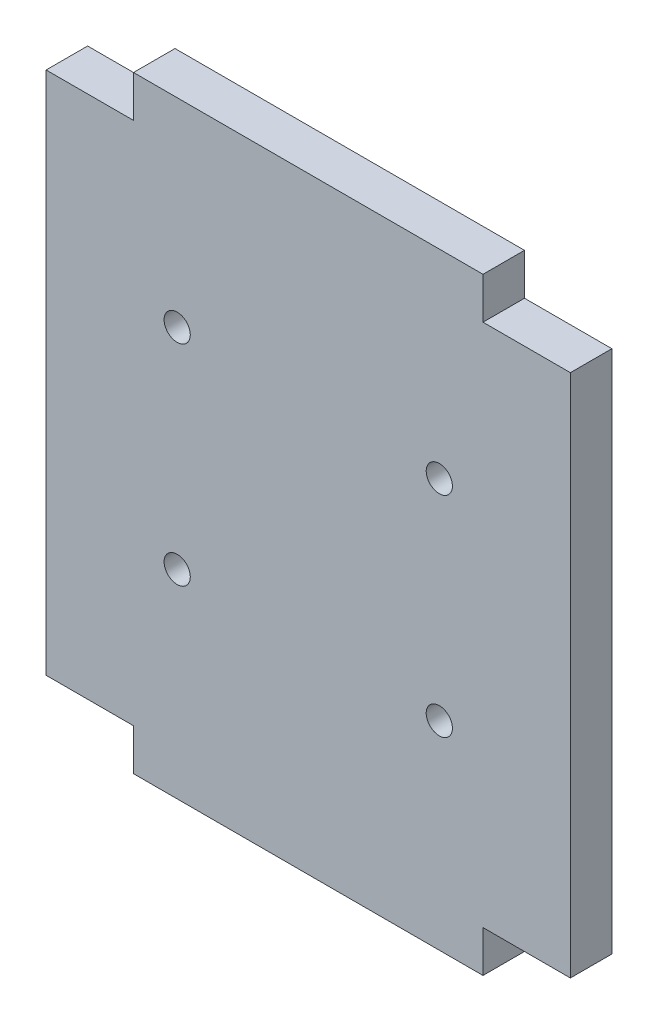
from build123d import *

# Parameters (mm, degrees)
SKETCH1_W               = 60
SKETCH1_H               = 69.5
BOSS_EXTRUDE1_DEPTH     = 4.75
SKETCH2_W               = 10
SKETCH2_H               = 4.75
CUT_EXTRUDE1_DEPTH      = 1
CUT_EXTRUDE1_DEPTH_BACK = 5.75
SKETCH3_R               = 1.5
CUT_EXTRUDE2_DEPTH      = 1
CUT_EXTRUDE2_DEPTH_BACK = 5.75


with BuildPart() as part:
    # Sketch1 → Boss-Extrude1 (new body)
    with BuildSketch(Plane.XY):
        Rectangle(SKETCH1_W, SKETCH1_H)
    extrude(amount=BOSS_EXTRUDE1_DEPTH)

    # Sketch2 → Cut-Extrude1 (cut, two sides)
    with BuildSketch(Plane.XY.offset(4.75)) as cut_extrude1_sk:
        with Locations((-25, 32.375)):
            Rectangle(SKETCH2_W, SKETCH2_H)
        with Locations((-25, -32.375)):
            Rectangle(SKETCH2_W, SKETCH2_H)
        with Locations((25, -32.375)):
            Rectangle(SKETCH2_W, SKETCH2_H)
        with Locations((25, 32.375)):
            Rectangle(SKETCH2_W, SKETCH2_H)
    extrude(amount=CUT_EXTRUDE1_DEPTH, mode=Mode.SUBTRACT)
    extrude(cut_extrude1_sk.sketch, amount=-CUT_EXTRUDE1_DEPTH_BACK, mode=Mode.SUBTRACT)

    # Sketch3 → Cut-Extrude2 (cut, two sides)
    with BuildSketch(Plane.XY.offset(4.75)) as cut_extrude2_sk:
        with Locations((-15, 12)):
            Circle(SKETCH3_R)
        with Locations((-15, -12)):
            Circle(SKETCH3_R)
        with Locations((15, -12)):
            Circle(SKETCH3_R)
        with Locations((15, 12)):
            Circle(SKETCH3_R)
    extrude(amount=CUT_EXTRUDE2_DEPTH, mode=Mode.SUBTRACT)
    extrude(cut_extrude2_sk.sketch, amount=-CUT_EXTRUDE2_DEPTH_BACK, mode=Mode.SUBTRACT)


solid = part.part
